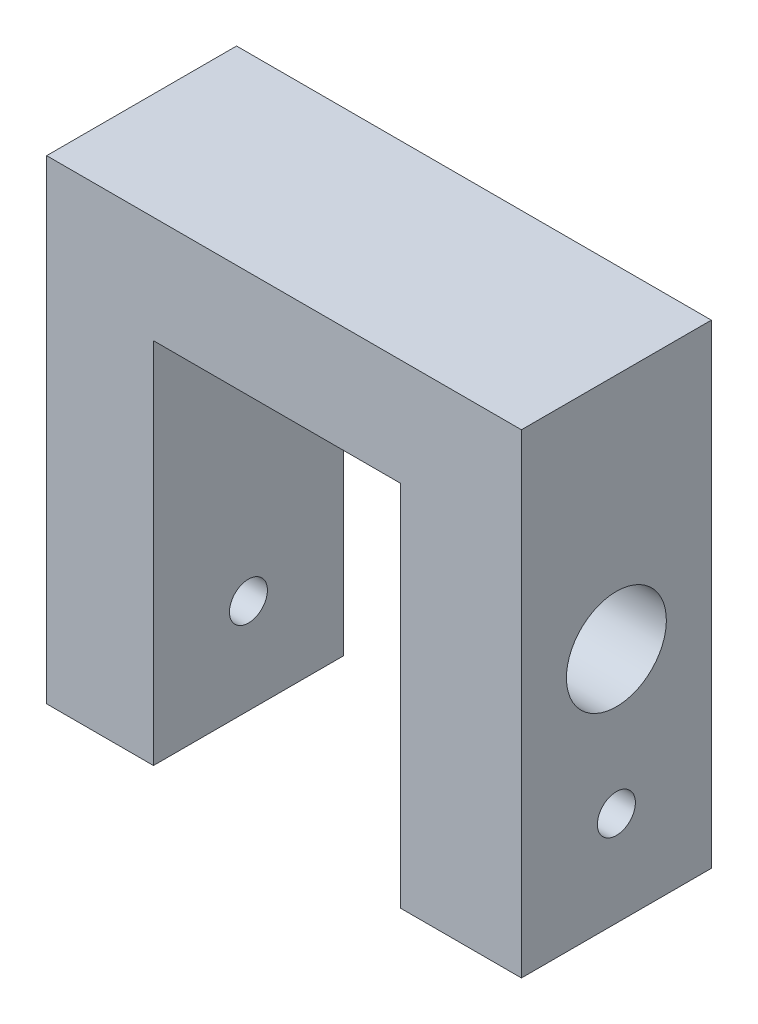
from build123d import *

# Parameters (mm, degrees)
EXTRUDE_2_DEPTH     = 16
SKETCH_3_R          = 4.21
CUT_EXTRUDE_1_DEPTH = 11
SKETCH_5_R          = 1.6
CUT_EXTRUDE_2_DEPTH = 40


with BuildPart() as part:
    # 草图2 → 凸台-拉伸2 (new body)
    with BuildSketch(Plane.XY):
        Polygon((-20, -20), (-20, 20), (20, 20), (20, -20), (9.8, -20), (9.8, 11), (-11, 11), (-11, -20), align=None)
    extrude(amount=EXTRUDE_2_DEPTH)

    # 草图3 → 切除-拉伸1 (cut)
    with BuildSketch(Plane(origin=(20, 0, 0), x_dir=(0, 0, -1), z_dir=(1, 0, 0))):
        with Locations((-8, 0)):
            Circle(SKETCH_3_R)
    extrude(amount=-CUT_EXTRUDE_1_DEPTH, mode=Mode.SUBTRACT)

    # 草图5 → 切除-拉伸2 (cut)
    with BuildSketch(Plane(origin=(20, 0, 0), x_dir=(0, 0, -1), z_dir=(1, 0, 0))):
        with Locations((-8, -12)):
            Circle(SKETCH_5_R)
    extrude(amount=-CUT_EXTRUDE_2_DEPTH, mode=Mode.SUBTRACT)


solid = part.part
